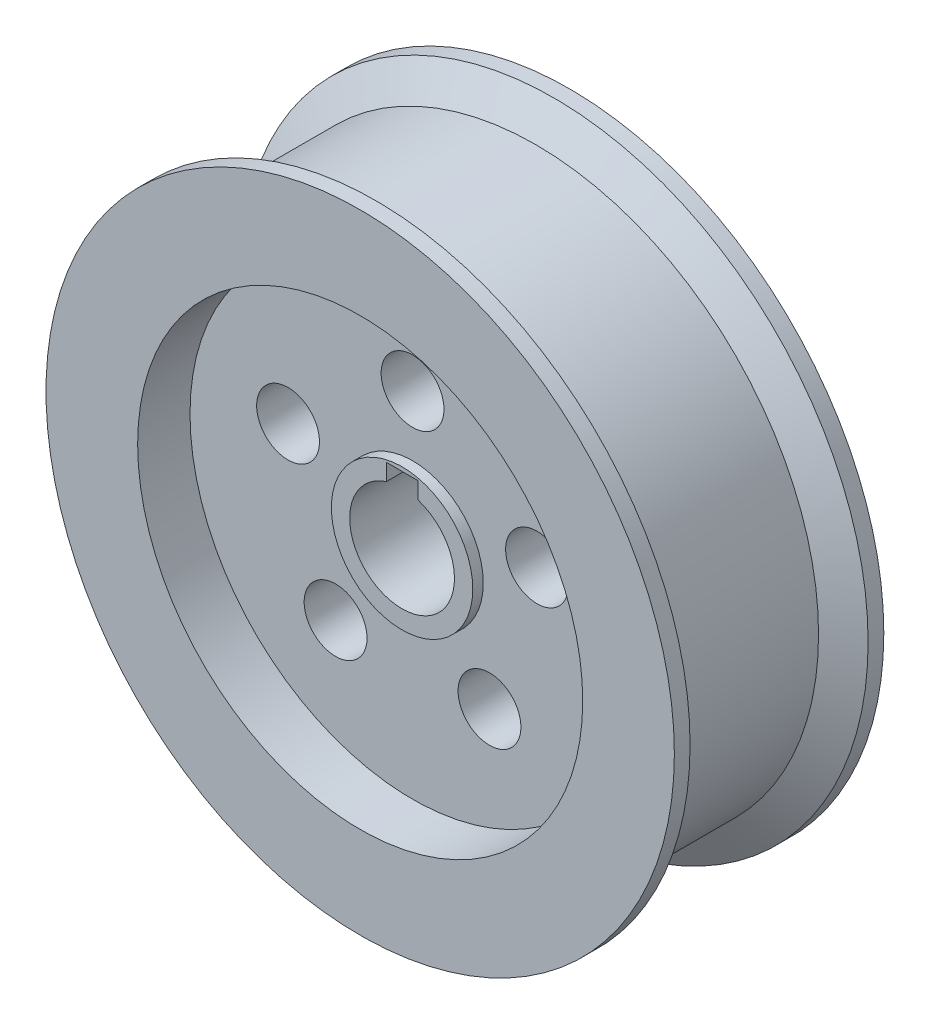
from build123d import *

# Parameters (mm, degrees)
SKETCH2_R                = 60
SKETCH2_R_2              = 10
BOSS_EXTRUDE1_DEPTH      = 20
SKETCH3_R                = 42.5
CUT_EXTRUDE1_DEPTH       = 10
CUT_EXTRUDE2_START       = -31
SKETCH4_R                = 6
CUT_EXTRUDE2_DEPTH       = 42
CIRPATTERN2_COUNT        = 5
SKETCH6_R                = 13.5
SKETCH6_R_2              = 10
BOSS_EXTRUDE3_DEPTH      = 2
BOSS_EXTRUDE3_DEPTH_BACK = 7
SKETCH8_W                = 6
SKETCH8_H                = 3.21
CUT_EXTRUDE3_DEPTH       = 11
CUT_EXTRUDE3_DEPTH_BACK  = 31


with BuildPart() as part:
    # Sketch2 → Boss-Extrude1 (new body, symmetric)
    with BuildSketch(Plane.XY):
        Circle(SKETCH2_R)
        Circle(SKETCH2_R_2, mode=Mode.SUBTRACT)
    extrude(amount=BOSS_EXTRUDE1_DEPTH, both=True)

    # Sketch3 → Cut-Extrude1 (cut)
    with BuildSketch(Plane.XY.offset(20)):
        Circle(SKETCH3_R)
    cut_extrude1 = extrude(amount=-CUT_EXTRUDE1_DEPTH, mode=Mode.SUBTRACT)

    # Mirror2: Cut-Extrude1 across plane
    add(cut_extrude1.mirror(Plane.XY), mode=Mode.SUBTRACT)

    # Sketch4 → Cut-Extrude2 (cut)
    with BuildSketch(Plane.XY.offset(10).offset(CUT_EXTRUDE2_START)):
        with Locations((0, 25)):
            Circle(SKETCH4_R)
    cut_extrude2 = extrude(amount=CUT_EXTRUDE2_DEPTH, mode=Mode.SUBTRACT)

    # CirPattern2: Cut-Extrude2 ×5 about axis
    cirpattern2_axis = Axis((0, 0, 0), (0, 0, 1))
    for i in range(1, CIRPATTERN2_COUNT):
        add(cut_extrude2.rotate(cirpattern2_axis, i * 360 / CIRPATTERN2_COUNT), mode=Mode.SUBTRACT)

    # Sketch5 → Cut-Revolve1 (revolve, cut)
    with BuildSketch(Plane(origin=(0, 0, 0), x_dir=(1, 0, 0), z_dir=(0, 1, 0))):
        Polygon((54, 13.535898385), (60, 17), (60, -17), (54, -13.535898385), align=None)
    revolve(axis=Axis((0, 0, 0), (0, 0, -1)), mode=Mode.SUBTRACT)

    # Sketch6 → Boss-Extrude3 (add, two sides)
    with BuildSketch(Plane.XY.offset(10)) as boss_extrude3_sk:
        Circle(SKETCH6_R)
        Circle(SKETCH6_R_2, mode=Mode.SUBTRACT)
    extrude(amount=BOSS_EXTRUDE3_DEPTH)
    extrude(boss_extrude3_sk.sketch, amount=-BOSS_EXTRUDE3_DEPTH_BACK)

    # Sketch8 → Cut-Extrude3 (cut, two sides)
    with BuildSketch(Plane(origin=(0, 0, -10), x_dir=(-1, 0, 0), z_dir=(0, 0, -1))) as cut_extrude3_sk:
        with Locations((0, 11.121882551)):
            Rectangle(SKETCH8_W, SKETCH8_H)
    extrude(amount=CUT_EXTRUDE3_DEPTH, mode=Mode.SUBTRACT)
    extrude(cut_extrude3_sk.sketch, amount=-CUT_EXTRUDE3_DEPTH_BACK, mode=Mode.SUBTRACT)


solid = part.part
